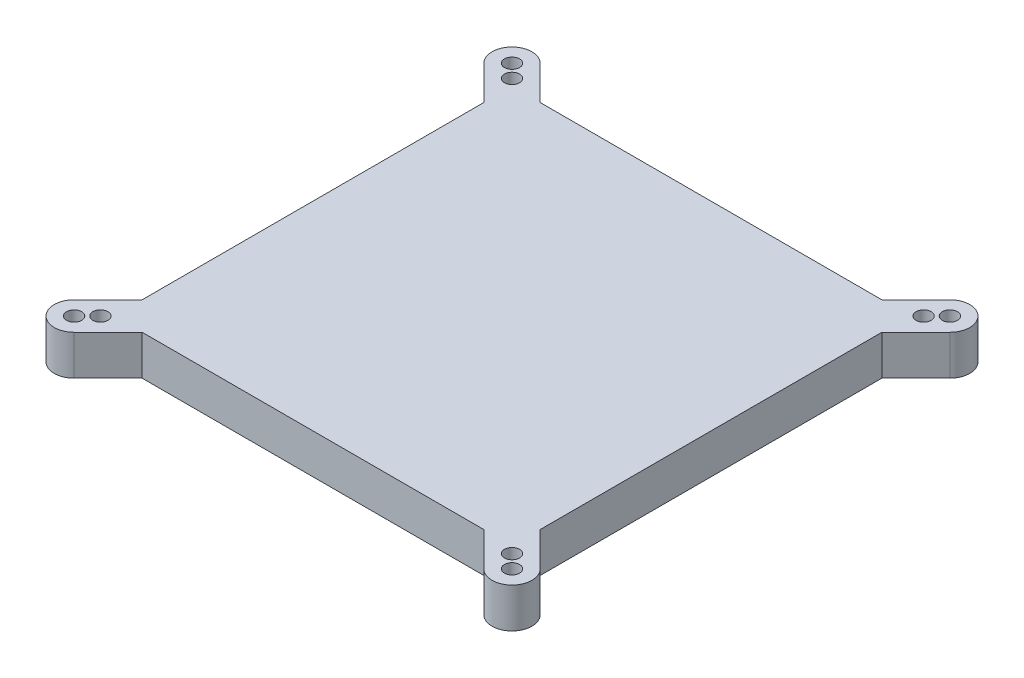
from build123d import *

# Parameters (mm, degrees)
SKETCH1_W               = 200
SKETCH1_H               = 200
BOSS_EXTRUDE1_DEPTH     = 20
SKETCH2_R               = 3.7970867
BOSS_EXTRUDE2_DEPTH     = 20
MIRROR4_COPY_1_SKETCH_R = 3.7970867
MIRROR4_COPY_1_DEPTH    = 20


with BuildPart() as part:
    # Sketch1 → Boss-Extrude1 (new body)
    with BuildSketch(Plane(origin=(0, 0, 0), x_dir=(1, 0, 0), z_dir=(0, 1, 0))):
        with Locations((100, 100)):
            Rectangle(SKETCH1_W, SKETCH1_H)
    extrude(amount=BOSS_EXTRUDE1_DEPTH)

    # Sketch2 → Boss-Extrude2 (add)
    with BuildSketch(Plane.XZ):
        with BuildLine():
            Line((0, -14.142135624), (-17.087625271, 2.945489647))
            ThreePointArc((-17.087625271, 2.945489647), (-17.087625271, 17.087625271), (-2.945489647, 17.087625271))
            Line((-2.945489647, 17.087625271), (14.142135624, 0))
            Line((14.142135624, 0), (0, 0))
            Line((0, 0), (0, -14.142135624))
        make_face()
        with Locations((-10.016557459, 10.016557459)):
            Circle(SKETCH2_R, mode=Mode.SUBTRACT)
        with Locations((-3.415367361, 3.415367361)):
            Circle(SKETCH2_R, mode=Mode.SUBTRACT)
    boss_extrude2 = extrude(amount=-BOSS_EXTRUDE2_DEPTH)

    # Mirror3: Boss-Extrude2 across plane
    add(boss_extrude2.mirror(Plane(origin=(100, 0, 0), x_dir=(0, 0, 1), z_dir=(1, 0, 0))))

    # Mirror4: Boss-Extrude2 across plane
    add(boss_extrude2.mirror(Plane(origin=(0, 0, -100), x_dir=(1, 0, 0), z_dir=(0, 0, -1))))

    # Mirror4 copy 1 sketch → Mirror4 copy 1 (add)
    with BuildSketch(Plane(origin=(200, 0, -200), x_dir=(-1, 0, 0), z_dir=(0, -1, 0))):
        with BuildLine():
            Line((0, -14.142135624), (-17.087625271, 2.945489647))
            ThreePointArc((-17.087625271, 2.945489647), (-17.087625271, 17.087625271), (-2.945489647, 17.087625271))
            Line((-2.945489647, 17.087625271), (14.142135624, 0))
            Line((14.142135624, 0), (0, 0))
            Line((0, 0), (0, -14.142135624))
        make_face()
        with Locations((-10.016557459, 10.016557459)):
            Circle(MIRROR4_COPY_1_SKETCH_R, mode=Mode.SUBTRACT)
        with Locations((-3.415367361, 3.415367361)):
            Circle(MIRROR4_COPY_1_SKETCH_R, mode=Mode.SUBTRACT)
    extrude(amount=-MIRROR4_COPY_1_DEPTH)


solid = part.part
